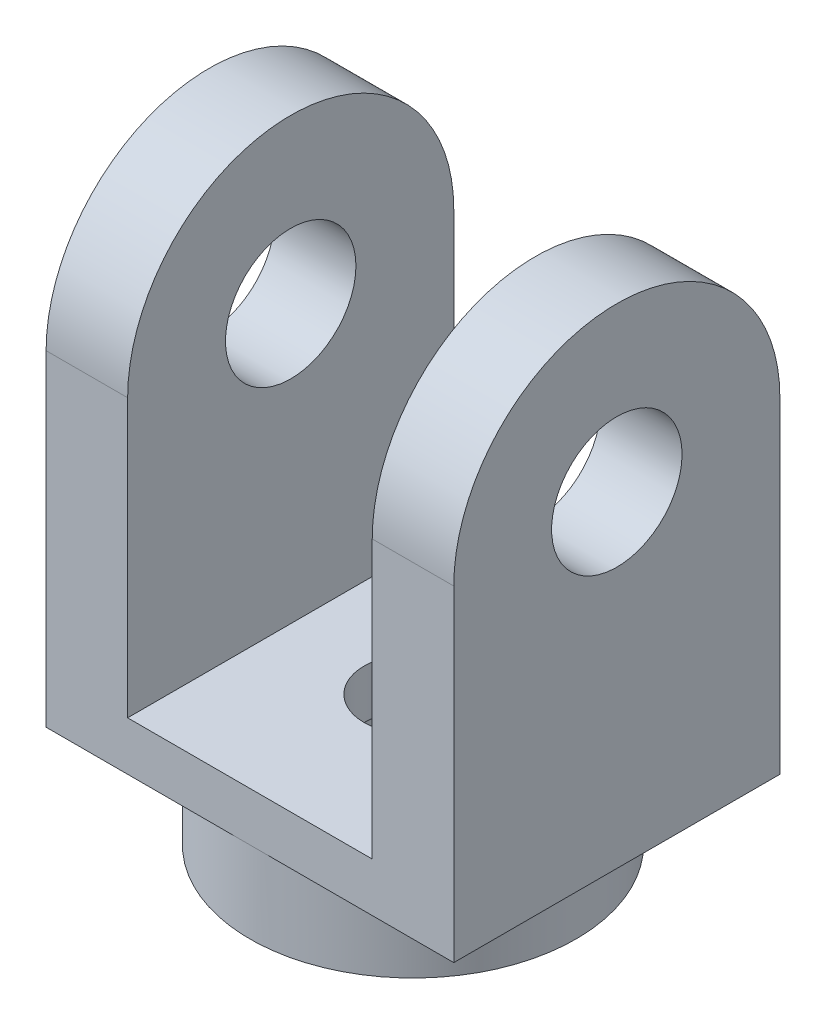
from build123d import *

# Parameters (mm, degrees)
SKETCH1_W           = 125
SKETCH1_H           = 100
BOSS_EXTRUDE1_DEPTH = 15
SKETCH2_R           = 50
SKETCH2_R_2         = 37.5
BOSS_EXTRUDE2_DEPTH = 25
SKETCH5_R           = 20
BOSS_EXTRUDE3_DEPTH = 25
SKETCH6_R           = 15
CUT_EXTRUDE2_DEPTH  = 15


with BuildPart() as part:
    # Sketch1 → Boss-Extrude1 (new body)
    with BuildSketch(Plane(origin=(0, 0, 0), x_dir=(1, 0, 0), z_dir=(0, 1, 0))):
        Rectangle(SKETCH1_W, SKETCH1_H)
    boss_extrude1 = extrude(amount=BOSS_EXTRUDE1_DEPTH)

    # Sketch2 → Boss-Extrude2 (add)
    with BuildSketch(Plane.XZ):
        Circle(SKETCH2_R)
        Circle(SKETCH2_R_2, mode=Mode.SUBTRACT)
    extrude(amount=BOSS_EXTRUDE2_DEPTH)

    # Sketch5 → Boss-Extrude3 (add)
    with BuildSketch(Plane(origin=(62.5, 0, 0), x_dir=(0, 0, -1), z_dir=(1, 0, 0))):
        with BuildLine():
            ThreePointArc((-50, 100), (0, 150), (50, 100))
            Line((50, 100), (50, 15))
            Line((50, 15), (-50, 15))
            Line((-50, 15), (-50, 100))
        make_face()
        with Locations((0, 100)):
            Circle(SKETCH5_R, mode=Mode.SUBTRACT)
    boss_extrude3 = extrude(amount=-BOSS_EXTRUDE3_DEPTH)

    # Mirror1: Boss-Extrude1, Boss-Extrude3 across plane
    add(boss_extrude1.mirror(Plane(origin=(0, 0, 0), x_dir=(0, 0, 1), z_dir=(1, 0, 0))))
    add(boss_extrude3.mirror(Plane(origin=(0, 0, 0), x_dir=(0, 0, 1), z_dir=(1, 0, 0))))

    # Sketch6 → Cut-Extrude2 (cut)
    with BuildSketch(Plane.XZ):
        Circle(SKETCH6_R)
    extrude(amount=-CUT_EXTRUDE2_DEPTH, mode=Mode.SUBTRACT)


solid = part.part
